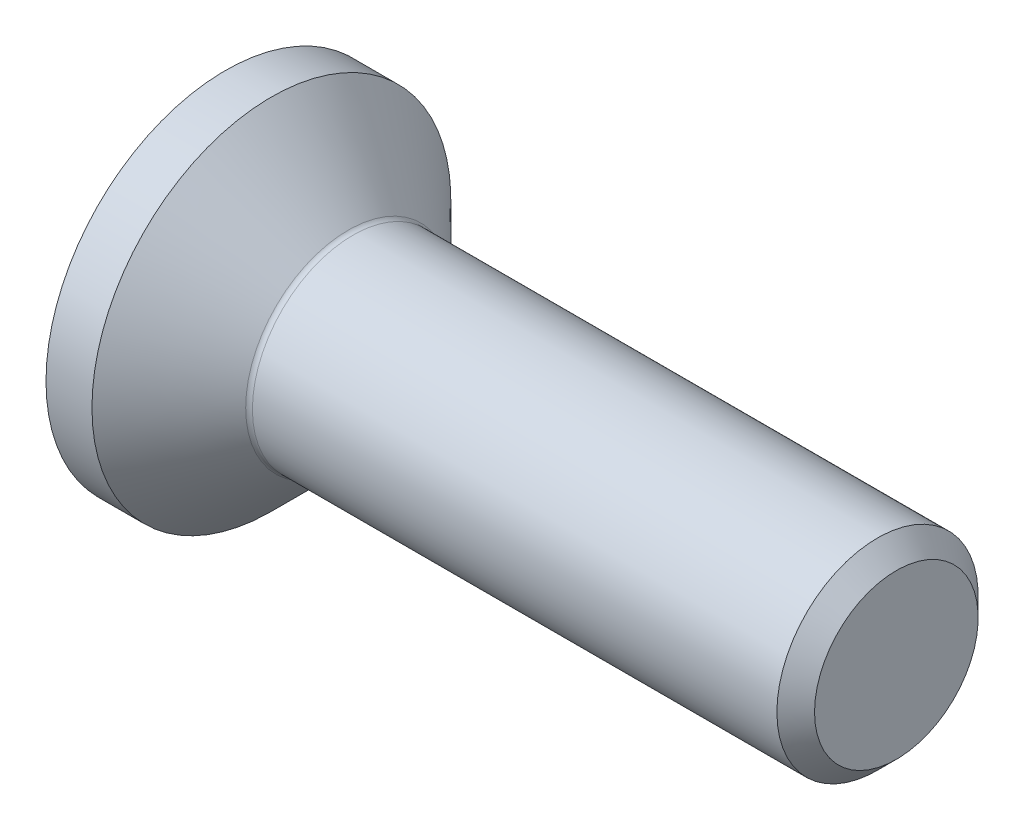
from build123d import *

# Parameters (mm, degrees)
FILLET1_R   = 0.1
HEX_2_DEPTH = 1.1


with BuildPart() as part:
    # BodySke → BaseBody (revolve)
    with BuildSketch(Plane.XY):
        Polygon((0, 0), (0, 2.675), (0.685, 2.675), (1.86, 1.5), (9.7195, 1.5), (10, 1.2195), (10, 0), align=None)
    revolve(axis=Axis((0, 0, 0), (1, 0, 0)))

    # Fillet1
    fillet1_edges = [part.edges().sort_by_distance(p)[0] for p in [
        (1.86, -1.5, 0),
    ]]
    fillet(fillet1_edges, radius=FILLET1_R)

    # Sketch2 → PreBroach (revolve, cut)
    with BuildSketch(Plane.XY):
        Polygon((0, 1), (1.1, 1), (1.677350269, 0), (0, 0), align=None)
    revolve(axis=Axis((0, 0, 0), (1, 0, 0)), mode=Mode.SUBTRACT)

    # Sketch3 → Hex 2 (cut)
    with BuildSketch(Plane.ZY):
        Polygon((-1, -0.577350269), (-1, 0.577350269), (0, 1.154700538), (1, 0.577350269), (1, -0.577350269), (0, -1.154700538), align=None)
    extrude(amount=-HEX_2_DEPTH, mode=Mode.SUBTRACT)


solid = part.part
